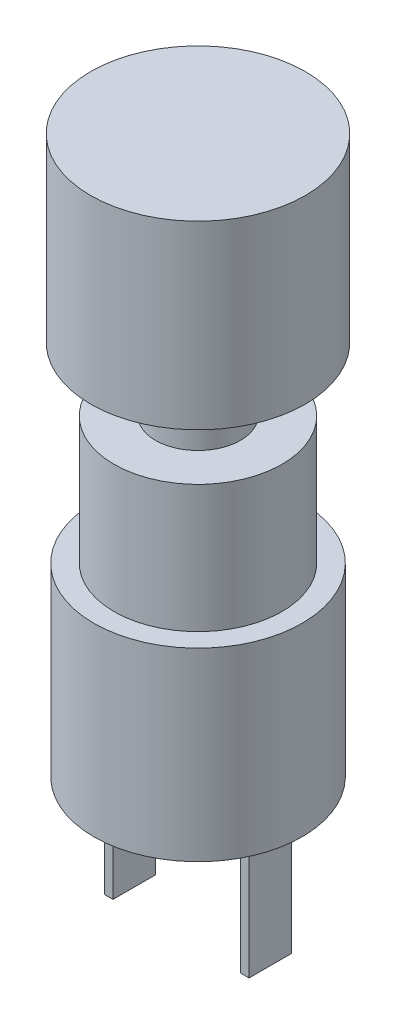
from build123d import *

# Parameters (mm, degrees)
ESQUISSE2_R        = 4.9
BOSS_EXTRU_1_DEPTH = 8.7
ESQUISSE3_R        = 3.95
BOSS_EXTRU_2_DEPTH = 6
ESQUISSE4_R        = 2
BOSS_EXTRU_3_DEPTH = 3
ESQUISSE5_R        = 5.05
BOSS_EXTRU_4_DEPTH = 8.5
ESQUISSE6_W        = 0.4
ESQUISSE6_H        = 2
BOSS_EXTRU_5_DEPTH = 6


with BuildPart() as part:
    # Esquisse2 → Boss.-Extru.1 (new body)
    with BuildSketch(Plane(origin=(0, 0, 0), x_dir=(1, 0, 0), z_dir=(0, 1, 0))):
        Circle(ESQUISSE2_R)
    extrude(amount=BOSS_EXTRU_1_DEPTH)

    # Esquisse3 → Boss.-Extru.2 (add)
    with BuildSketch(Plane(origin=(0, 8.7, 0), x_dir=(1, 0, 0), z_dir=(0, 1, 0))):
        Circle(ESQUISSE3_R)
    extrude(amount=BOSS_EXTRU_2_DEPTH)

    # Esquisse4 → Boss.-Extru.3 (add)
    with BuildSketch(Plane(origin=(0, 14.7, 0), x_dir=(1, 0, 0), z_dir=(0, 1, 0))):
        Circle(ESQUISSE4_R)
    extrude(amount=BOSS_EXTRU_3_DEPTH)

    # Esquisse5 → Boss.-Extru.4 (add)
    with BuildSketch(Plane(origin=(0, 17.7, 0), x_dir=(1, 0, 0), z_dir=(0, 1, 0))):
        Circle(ESQUISSE5_R)
    extrude(amount=BOSS_EXTRU_4_DEPTH)

    # Esquisse6 → Boss.-Extru.5 (add)
    with BuildSketch(Plane.XZ):
        with Locations((-3.2, 0)):
            Rectangle(ESQUISSE6_W, ESQUISSE6_H)
        with Locations((3.2, 0)):
            Rectangle(ESQUISSE6_W, ESQUISSE6_H)
    extrude(amount=BOSS_EXTRU_5_DEPTH)


solid = part.part
